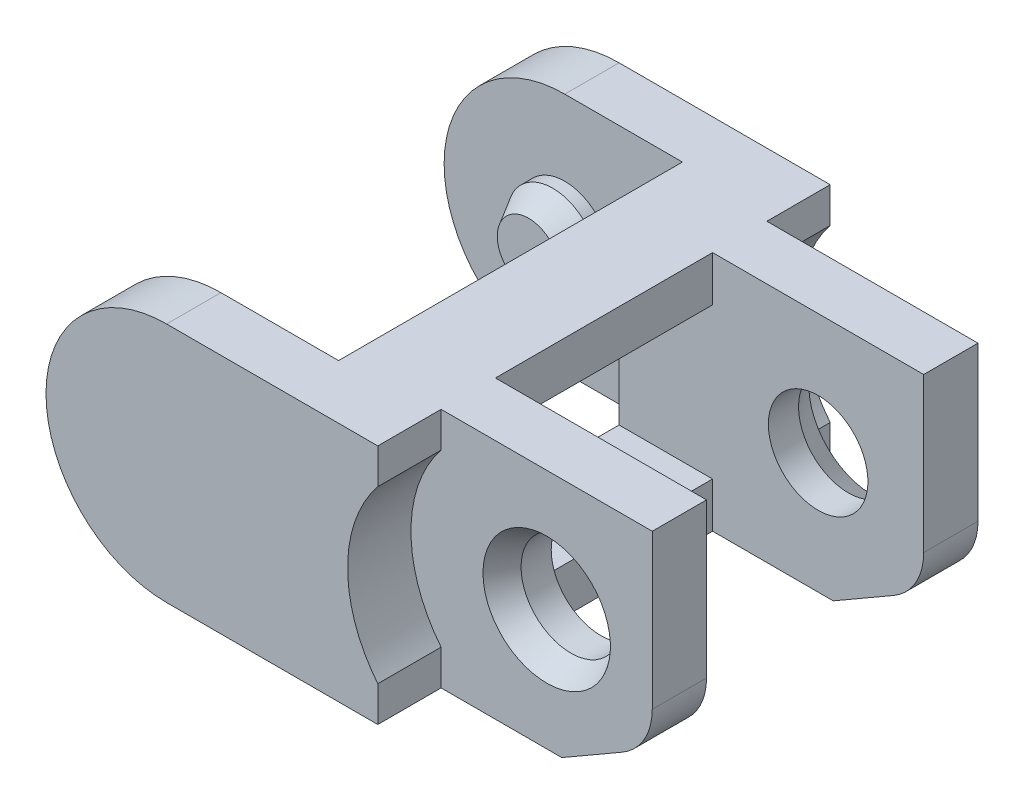
from build123d import *

# Parameters (mm, degrees)
RESSALTO_EXTRUS_O1_DEPTH   = 7.5
ESBO_O2_W                  = 7.9
ESBO_O2_H                  = 11.4
ESBO_O2_W_2                = 7
ESBO_O2_H_2                = 2.1
ESBO_O2_H_3                = 7.2
CORTE_EXTRUS_O1_DEPTH      = 1
CORTE_EXTRUS_O1_DEPTH_BACK = 9
ESBO_O3_W                  = 7.2
ESBO_O3_H                  = 5
CORTE_EXTRUS_O2_DEPTH      = 8
CORTE_EXTRUS_O2_DEPTH_BACK = 12
ESBO_O4_R                  = 1.65
CORTE_EXTRUS_O3_DEPTH      = 3.1
CORTE_EXTRUS_O3_DEPTH_BACK = 13.9
ESBO_O5_R                  = 1.5
RESSALTO_EXTRUS_O2_DEPTH   = 1.2
ESBO_O6_R                  = 4.5
CORTE_EXTRUS_O4_DEPTH      = 2.1
FILETE1_R                  = 2
CHANFRO1_SIZE              = 0.8
CHANFRO1_SIZE2             = 0.461880215
CHANFRO1_PART_2_SIZE       = 0.8
CHANFRO1_PART_2_SIZE2      = 0.461880215
CHANFRO1_PART_3_SIZE       = 0.8
CHANFRO1_PART_3_SIZE2      = 0.461880215
CHANFRO1_PART_4_SIZE       = 0.8
CHANFRO1_PART_4_SIZE2      = 0.461880215


with BuildPart() as part:
    # Esboço1 → Ressalto-extrusão1 (new body, symmetric)
    with BuildSketch(Plane.XY):
        with BuildLine():
            Line((-7, 0), (7, 0))
            Line((7, 0), (7, -6.267949192))
            Line((7, -6.267949192), (4, -8))
            Line((4, -8), (-7, -8))
            ThreePointArc((-7, -8), (-11, -4), (-7, 0))
        make_face()
    extrude(amount=RESSALTO_EXTRUS_O1_DEPTH, both=True)

    # Esboço2 → Corte-extrusão1 (cut, two sides)
    with BuildSketch(Plane(origin=(0, 0, 0), x_dir=(1, 0, 0), z_dir=(0, 1, 0))) as corte_extrus_o1_sk:
        with Locations((-7.05, 0)):
            Rectangle(ESBO_O2_W, ESBO_O2_H)
        with Locations((3.5, -6.45)):
            Rectangle(ESBO_O2_W_2, ESBO_O2_H_2)
        with Locations((3.5, 6.45)):
            Rectangle(ESBO_O2_W_2, ESBO_O2_H_2)
        with Locations((3.5, 0)):
            Rectangle(ESBO_O2_W_2, ESBO_O2_H_3)
    extrude(amount=CORTE_EXTRUS_O1_DEPTH, mode=Mode.SUBTRACT)
    extrude(corte_extrus_o1_sk.sketch, amount=-CORTE_EXTRUS_O1_DEPTH_BACK, mode=Mode.SUBTRACT)

    # Esboço3 → Corte-extrusão2 (cut, two sides)
    with BuildSketch(Plane(origin=(0, 0, 0), x_dir=(0, 0, -1), z_dir=(1, 0, 0))) as corte_extrus_o2_sk:
        with Locations((0, -4)):
            Rectangle(ESBO_O3_W, ESBO_O3_H)
    extrude(amount=CORTE_EXTRUS_O2_DEPTH, mode=Mode.SUBTRACT)
    extrude(corte_extrus_o2_sk.sketch, amount=-CORTE_EXTRUS_O2_DEPTH_BACK, mode=Mode.SUBTRACT)

    # Esboço4 → Corte-extrusão3 (cut, two sides)
    with BuildSketch(Plane(origin=(0, 0, -5.4), x_dir=(-1, 0, 0), z_dir=(0, 0, -1))) as corte_extrus_o3_sk:
        with Locations((-3.5, -4)):
            Circle(ESBO_O4_R)
    extrude(amount=CORTE_EXTRUS_O3_DEPTH, mode=Mode.SUBTRACT)
    extrude(corte_extrus_o3_sk.sketch, amount=-CORTE_EXTRUS_O3_DEPTH_BACK, mode=Mode.SUBTRACT)

    # Esboço5 → Ressalto-extrusão2 (add)
    with BuildSketch(Plane(origin=(0, 0, 5.7), x_dir=(-1, 0, 0), z_dir=(0, 0, -1))):
        with Locations((7, -4)):
            Circle(ESBO_O5_R)
    ressalto_extrus_o2 = extrude(amount=RESSALTO_EXTRUS_O2_DEPTH)

    # Esboço6 → Corte-extrusão4 (cut)
    with BuildSketch(Plane.XY.offset(7.5)):
        with Locations((3.5, -4)):
            Circle(ESBO_O6_R)
    corte_extrus_o4 = extrude(amount=-CORTE_EXTRUS_O4_DEPTH, mode=Mode.SUBTRACT)

    # Espelhar1: Ressalto-extrusão2, Corte-extrusão4 across plane
    add(ressalto_extrus_o2.mirror(Plane.XY))
    add(corte_extrus_o4.mirror(Plane.XY), mode=Mode.SUBTRACT)

    # Filete1
    filete1_edges = [part.edges().sort_by_distance(p)[0] for p in [
        (7, -6.267949192, 4.5),
        (7, -6.267949192, -4.5),
    ]]
    fillet(filete1_edges, radius=FILETE1_R)

    # Chanfro1
    chanfro1_edges = [part.edges().sort_by_distance(p)[0] for p in [
        (5.15, -4, -5.4),
    ]]
    chanfro1_side = [part.faces().sort_by_distance(p)[0] for p in [
        (5.15, -4, -4.5),
    ]]
    chamfer(chanfro1_edges, length=CHANFRO1_SIZE, length2=CHANFRO1_SIZE2, reference=chanfro1_side[0])

    # Chanfro1 part 2
    chanfro1_part_2_edges = [part.edges().sort_by_distance(p)[0] for p in [
        (5.15, -4, 5.4),
    ]]
    chanfro1_part_2_side = [part.faces().sort_by_distance(p)[0] for p in [
        (5.15, -4, 4.5),
    ]]
    chamfer(chanfro1_part_2_edges, length=CHANFRO1_PART_2_SIZE, length2=CHANFRO1_PART_2_SIZE2, reference=chanfro1_part_2_side[0])

    # Chanfro1 part 3
    chanfro1_part_3_edges = [part.edges().sort_by_distance(p)[0] for p in [
        (-5.5, -4, 4.5),
    ]]
    chanfro1_part_3_side = [part.faces().sort_by_distance(p)[0] for p in [
        (-5.5, -4, 5.1),
    ]]
    chamfer(chanfro1_part_3_edges, length=CHANFRO1_PART_3_SIZE, length2=CHANFRO1_PART_3_SIZE2, reference=chanfro1_part_3_side[0])

    # Chanfro1 part 4
    chanfro1_part_4_edges = [part.edges().sort_by_distance(p)[0] for p in [
        (-5.5, -4, -4.5),
    ]]
    chanfro1_part_4_side = [part.faces().sort_by_distance(p)[0] for p in [
        (-5.5, -4, -5.1),
    ]]
    chamfer(chanfro1_part_4_edges, length=CHANFRO1_PART_4_SIZE, length2=CHANFRO1_PART_4_SIZE2, reference=chanfro1_part_4_side[0])


solid = part.part
